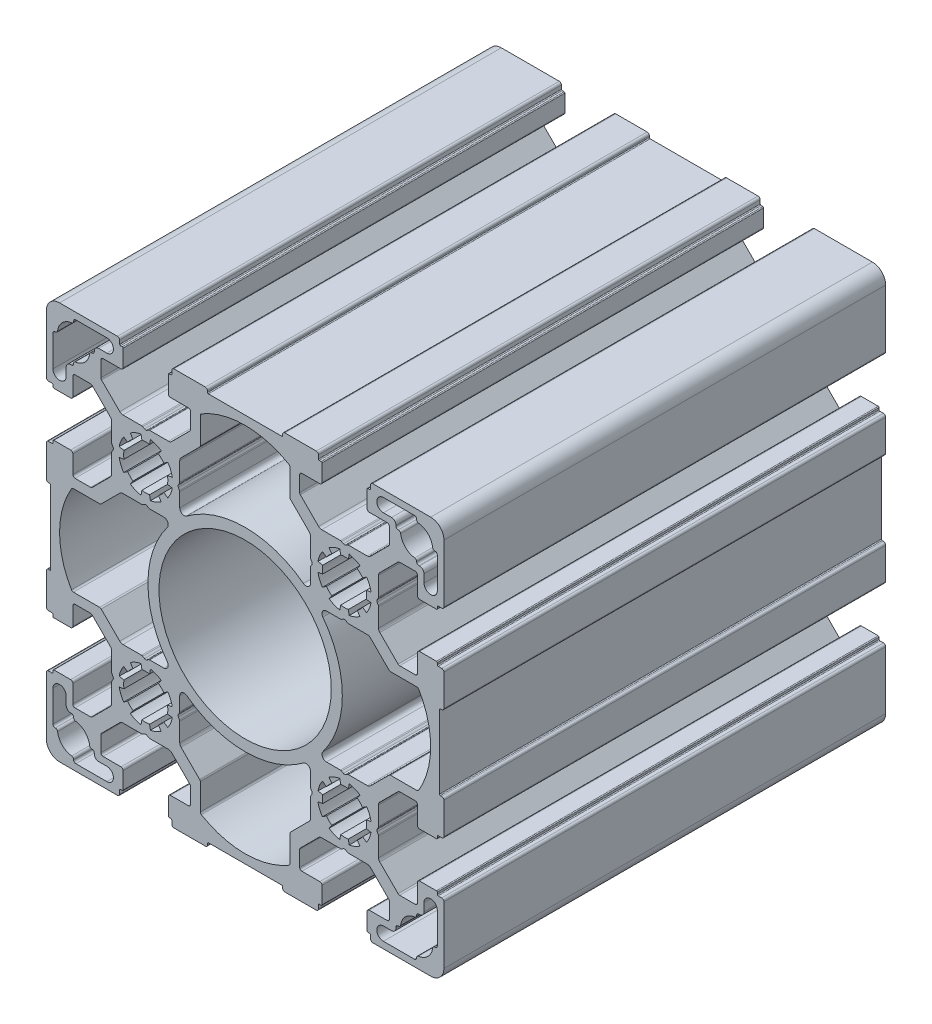
from build123d import *

# Parameters (mm, degrees)
SKETCH_1_R      = 19.5
EXTRUDE_1_DEPTH = 100


with BuildPart() as part:
    # Эскиз1 → Бобышка-Вытянуть1 (new body)
    with BuildSketch(Plane.XY):
        with BuildLine():
            Line((-35.141853673, 36.152210307), (-35.141853673, 40.388068593))
            ThreePointArc((-35.141853673, 40.388068593), (-35.21797414, 40.770752026), (-35.434746892, 41.095175374))
            Line((-35.434746892, 41.095175374), (-37.681504654, 43.341933137))
            Line((-37.681504654, 43.341933137), (-39.566246974, 45.226675456))
            ThreePointArc((-39.566246974, 45.226675456), (-39.728458648, 45.335061832), (-39.919800364, 45.373122066))
            Line((-39.919800364, 45.373122066), (-43.441373239, 45.373122066))
            ThreePointArc((-43.441373239, 45.373122066), (-43.79492663, 45.226675456), (-43.941373239, 44.873122066))
            Line((-43.941373239, 44.873122066), (-43.941373239, 40.823122066))
            ThreePointArc((-43.941373239, 40.823122066), (-44.087819849, 40.469568675), (-44.441373239, 40.323122066))
            Line((-44.441373239, 40.323122066), (-48.241373239, 40.323122066))
            ThreePointArc((-48.241373239, 40.323122066), (-48.382794596, 40.381700709), (-48.441373239, 40.523122066))
            Line((-48.441373239, 40.523122066), (-48.441373239, 40.923122066))
            ThreePointArc((-48.441373239, 40.923122066), (-48.499951883, 41.064543422), (-48.641373239, 41.123122066))
            Line((-48.641373239, 41.123122066), (-49.441373239, 41.123122066))
            ThreePointArc((-49.441373239, 41.123122066), (-49.79492663, 41.269568675), (-49.941373239, 41.623122066))
            Line((-49.941373239, 41.623122066), (-49.941373239, 54.723122066))
            ThreePointArc((-49.941373239, 54.723122066), (-49.062693583, 56.844442409), (-46.941373239, 57.723122066))
            Line((-46.941373239, 57.723122066), (-33.841373239, 57.723122066))
            ThreePointArc((-33.841373239, 57.723122066), (-33.487819849, 57.576675456), (-33.341373239, 57.223122066))
            Line((-33.341373239, 57.223122066), (-33.341373239, 56.423122066))
            ThreePointArc((-33.341373239, 56.423122066), (-33.282794596, 56.281700709), (-33.141373239, 56.223122066))
            Line((-33.141373239, 56.223122066), (-32.741373239, 56.223122066))
            ThreePointArc((-32.741373239, 56.223122066), (-32.599951883, 56.164543422), (-32.541373239, 56.023122066))
            Line((-32.541373239, 56.023122066), (-32.541373239, 52.223122066))
            ThreePointArc((-32.541373239, 52.223122066), (-32.687819849, 51.869568675), (-33.041373239, 51.723122066))
            Line((-33.041373239, 51.723122066), (-37.091373239, 51.723122066))
            ThreePointArc((-37.091373239, 51.723122066), (-37.44492663, 51.576675456), (-37.591373239, 51.223122066))
            Line((-37.591373239, 51.223122066), (-37.591373239, 47.70154919))
            ThreePointArc((-37.591373239, 47.70154919), (-37.553313006, 47.510207474), (-37.44492663, 47.3479958))
            Line((-37.44492663, 47.3479958), (-35.560184311, 45.463253481))
            Line((-35.560184311, 45.463253481), (-33.313426548, 43.216495718))
            ThreePointArc((-33.313426548, 43.216495718), (-32.989003199, 42.999722967), (-32.606319767, 42.923602499))
            Line((-32.606319767, 42.923602499), (-28.370461481, 42.923602499))
            ThreePointArc((-28.370461481, 42.923602499), (-28.241051958, 42.906565412), (-28.120461481, 42.856615201))
            Line((-28.120461481, 42.856615201), (-27.691373239, 42.608880989))
            ThreePointArc((-27.691373239, 42.608880989), (-27.441373239, 42.541893691), (-27.191373239, 42.608880989))
            Line((-27.191373239, 42.608880989), (-26.762284998, 42.856615201))
            ThreePointArc((-26.762284998, 42.856615201), (-26.64169452, 42.906565412), (-26.512284998, 42.923602499))
            Line((-26.512284998, 42.923602499), (-22.276426712, 42.923602499))
            ThreePointArc((-22.276426712, 42.923602499), (-21.89374328, 42.999722967), (-21.569319931, 43.216495718))
            Line((-21.569319931, 43.216495718), (-19.322562168, 45.463253481))
            Line((-19.322562168, 45.463253481), (-17.437819849, 47.3479958))
            ThreePointArc((-17.437819849, 47.3479958), (-17.329433473, 47.510207474), (-17.291373239, 47.70154919))
            Line((-17.291373239, 47.70154919), (-17.291373239, 51.223122066))
            ThreePointArc((-17.291373239, 51.223122066), (-17.437819849, 51.576675456), (-17.791373239, 51.723122066))
            Line((-17.791373239, 51.723122066), (-21.841373239, 51.723122066))
            ThreePointArc((-21.841373239, 51.723122066), (-22.19492663, 51.869568675), (-22.341373239, 52.223122066))
            Line((-22.341373239, 52.223122066), (-22.341373239, 56.023122066))
            ThreePointArc((-22.341373239, 56.023122066), (-22.282794596, 56.164543422), (-22.141373239, 56.223122066))
            Line((-22.141373239, 56.223122066), (-21.741373239, 56.223122066))
            ThreePointArc((-21.741373239, 56.223122066), (-21.599951883, 56.281700709), (-21.541373239, 56.423122066))
            Line((-21.541373239, 56.423122066), (-21.541373239, 57.223122066))
            ThreePointArc((-21.541373239, 57.223122066), (-21.39492663, 57.576675456), (-21.041373239, 57.723122066))
            Line((-21.041373239, 57.723122066), (-13.941373239, 57.723122066))
            ThreePointArc((-13.941373239, 57.723122066), (-13.587819849, 57.576675456), (-13.441373239, 57.223122066))
            Line((-13.441373239, 57.223122066), (-13.441373239, 56.923122066))
            ThreePointArc((-13.441373239, 56.923122066), (-13.382794596, 56.781700709), (-13.241373239, 56.723122066))
            Line((-13.241373239, 56.723122066), (3.358626761, 56.723122066))
            ThreePointArc((3.358626761, 56.723122066), (3.500048117, 56.781700709), (3.558626761, 56.923122066))
            Line((3.558626761, 56.923122066), (3.558626761, 57.223122066))
            ThreePointArc((3.558626761, 57.223122066), (3.70507337, 57.576675456), (4.058626761, 57.723122066))
            Line((4.058626761, 57.723122066), (11.158626761, 57.723122066))
            ThreePointArc((11.158626761, 57.723122066), (11.512180151, 57.576675456), (11.658626761, 57.223122066))
            Line((11.658626761, 57.223122066), (11.658626761, 56.423122066))
            ThreePointArc((11.658626761, 56.423122066), (11.717205404, 56.281700709), (11.858626761, 56.223122066))
            Line((11.858626761, 56.223122066), (12.258626761, 56.223122066))
            ThreePointArc((12.258626761, 56.223122066), (12.400048117, 56.164543422), (12.458626761, 56.023122066))
            Line((12.458626761, 56.023122066), (12.458626761, 52.223122066))
            ThreePointArc((12.458626761, 52.223122066), (12.312180151, 51.869568675), (11.958626761, 51.723122066))
            Line((11.958626761, 51.723122066), (7.908626761, 51.723122066))
            ThreePointArc((7.908626761, 51.723122066), (7.55507337, 51.576675456), (7.408626761, 51.223122066))
            Line((7.408626761, 51.223122066), (7.408626761, 47.70154919))
            ThreePointArc((7.408626761, 47.70154919), (7.446686994, 47.510207474), (7.55507337, 47.3479958))
            Line((7.55507337, 47.3479958), (9.439815689, 45.463253481))
            Line((9.439815689, 45.463253481), (11.686573452, 43.216495718))
            ThreePointArc((11.686573452, 43.216495718), (12.010996801, 42.999722967), (12.393680233, 42.923602499))
            Line((12.393680233, 42.923602499), (16.629538519, 42.923602499))
            ThreePointArc((16.629538519, 42.923602499), (16.758948042, 42.906565412), (16.879538519, 42.856615201))
            Line((16.879538519, 42.856615201), (17.308626761, 42.608880989))
            ThreePointArc((17.308626761, 42.608880989), (17.558626761, 42.541893691), (17.808626761, 42.608880989))
            Line((17.808626761, 42.608880989), (18.237715002, 42.856615201))
            ThreePointArc((18.237715002, 42.856615201), (18.35830548, 42.906565412), (18.487715002, 42.923602499))
            Line((18.487715002, 42.923602499), (22.723573288, 42.923602499))
            ThreePointArc((22.723573288, 42.923602499), (23.10625672, 42.999722967), (23.430680069, 43.216495718))
            Line((23.430680069, 43.216495718), (25.677437832, 45.463253481))
            Line((25.677437832, 45.463253481), (27.562180151, 47.3479958))
            ThreePointArc((27.562180151, 47.3479958), (27.670566527, 47.510207474), (27.708626761, 47.70154919))
            Line((27.708626761, 47.70154919), (27.708626761, 51.223122066))
            ThreePointArc((27.708626761, 51.223122066), (27.562180151, 51.576675456), (27.208626761, 51.723122066))
            Line((27.208626761, 51.723122066), (23.158626761, 51.723122066))
            ThreePointArc((23.158626761, 51.723122066), (22.80507337, 51.869568675), (22.658626761, 52.223122066))
            Line((22.658626761, 52.223122066), (22.658626761, 56.023122066))
            ThreePointArc((22.658626761, 56.023122066), (22.717205404, 56.164543422), (22.858626761, 56.223122066))
            Line((22.858626761, 56.223122066), (23.258626761, 56.223122066))
            ThreePointArc((23.258626761, 56.223122066), (23.400048117, 56.281700709), (23.458626761, 56.423122066))
            Line((23.458626761, 56.423122066), (23.458626761, 57.223122066))
            ThreePointArc((23.458626761, 57.223122066), (23.60507337, 57.576675456), (23.958626761, 57.723122066))
            Line((23.958626761, 57.723122066), (37.058626761, 57.723122066))
            ThreePointArc((37.058626761, 57.723122066), (39.179947104, 56.844442409), (40.058626761, 54.723122066))
            Line((40.058626761, 54.723122066), (40.058626761, 41.623122066))
            ThreePointArc((40.058626761, 41.623122066), (39.912180151, 41.269568675), (39.558626761, 41.123122066))
            Line((39.558626761, 41.123122066), (38.758626761, 41.123122066))
            ThreePointArc((38.758626761, 41.123122066), (38.617205404, 41.064543422), (38.558626761, 40.923122066))
            Line((38.558626761, 40.923122066), (38.558626761, 40.523122066))
            ThreePointArc((38.558626761, 40.523122066), (38.500048117, 40.381700709), (38.358626761, 40.323122066))
            Line((38.358626761, 40.323122066), (34.558626761, 40.323122066))
            ThreePointArc((34.558626761, 40.323122066), (34.20507337, 40.469568675), (34.058626761, 40.823122066))
            Line((34.058626761, 40.823122066), (34.058626761, 44.873122066))
            ThreePointArc((34.058626761, 44.873122066), (33.912180151, 45.226675456), (33.558626761, 45.373122066))
            Line((33.558626761, 45.373122066), (30.037053885, 45.373122066))
            ThreePointArc((30.037053885, 45.373122066), (29.845712169, 45.335061832), (29.683500495, 45.226675456))
            Line((29.683500495, 45.226675456), (27.798758175, 43.341933137))
            Line((27.798758175, 43.341933137), (25.552000413, 41.095175374))
            ThreePointArc((25.552000413, 41.095175374), (25.335227661, 40.770752026), (25.259107194, 40.388068593))
            Line((25.259107194, 40.388068593), (25.259107194, 36.152210307))
            ThreePointArc((25.259107194, 36.152210307), (25.242070107, 36.022800785), (25.192119896, 35.902210307))
            Line((25.192119896, 35.902210307), (24.944385684, 35.473122066))
            ThreePointArc((24.944385684, 35.473122066), (24.877398386, 35.223122066), (24.944385684, 34.973122066))
            Line((24.944385684, 34.973122066), (25.192119896, 34.544033824))
            ThreePointArc((25.192119896, 34.544033824), (25.242070107, 34.423443347), (25.259107194, 34.294033824))
            Line((25.259107194, 34.294033824), (25.259107194, 30.058175538))
            ThreePointArc((25.259107194, 30.058175538), (25.335227661, 29.675492106), (25.552000413, 29.351068757))
            Line((25.552000413, 29.351068757), (27.798758175, 27.104310994))
            Line((27.798758175, 27.104310994), (29.683500495, 25.219568675))
            ThreePointArc((29.683500495, 25.219568675), (29.845712169, 25.111182299), (30.037053885, 25.073122066))
            Line((30.037053885, 25.073122066), (33.558626761, 25.073122066))
            ThreePointArc((33.558626761, 25.073122066), (33.912180151, 25.219568675), (34.058626761, 25.573122066))
            Line((34.058626761, 25.573122066), (34.058626761, 29.623122066))
            ThreePointArc((34.058626761, 29.623122066), (34.20507337, 29.976675456), (34.558626761, 30.123122066))
            Line((34.558626761, 30.123122066), (38.358626761, 30.123122066))
            ThreePointArc((38.358626761, 30.123122066), (38.500048117, 30.064543422), (38.558626761, 29.923122066))
            Line((38.558626761, 29.923122066), (38.558626761, 29.523122066))
            ThreePointArc((38.558626761, 29.523122066), (38.617205404, 29.381700709), (38.758626761, 29.323122066))
            Line((38.758626761, 29.323122066), (39.558626761, 29.323122066))
            ThreePointArc((39.558626761, 29.323122066), (39.912180151, 29.176675456), (40.058626761, 28.823122066))
            Line((40.058626761, 28.823122066), (40.058626761, 21.723122066))
            ThreePointArc((40.058626761, 21.723122066), (39.912180151, 21.369568675), (39.558626761, 21.223122066))
            Line((39.558626761, 21.223122066), (39.258626761, 21.223122066))
            ThreePointArc((39.258626761, 21.223122066), (39.117205404, 21.164543422), (39.058626761, 21.023122066))
            Line((39.058626761, 21.023122066), (39.058626761, 4.423122066))
            ThreePointArc((39.058626761, 4.423122066), (39.117205404, 4.281700709), (39.258626761, 4.223122066))
            Line((39.258626761, 4.223122066), (39.558626761, 4.223122066))
            ThreePointArc((39.558626761, 4.223122066), (39.912180151, 4.076675456), (40.058626761, 3.723122066))
            Line((40.058626761, 3.723122066), (40.058626761, -3.376877934))
            ThreePointArc((40.058626761, -3.376877934), (39.912180151, -3.730431325), (39.558626761, -3.876877934))
            Line((39.558626761, -3.876877934), (38.758626761, -3.876877934))
            ThreePointArc((38.758626761, -3.876877934), (38.617205404, -3.935456578), (38.558626761, -4.076877934))
            Line((38.558626761, -4.076877934), (38.558626761, -4.476877934))
            ThreePointArc((38.558626761, -4.476877934), (38.500048117, -4.618299291), (38.358626761, -4.676877934))
            Line((38.358626761, -4.676877934), (34.558626761, -4.676877934))
            ThreePointArc((34.558626761, -4.676877934), (34.20507337, -4.530431325), (34.058626761, -4.176877934))
            Line((34.058626761, -4.176877934), (34.058626761, -0.126877934))
            ThreePointArc((34.058626761, -0.126877934), (33.912180151, 0.226675456), (33.558626761, 0.373122066))
            Line((33.558626761, 0.373122066), (30.037053885, 0.373122066))
            ThreePointArc((30.037053885, 0.373122066), (29.845712169, 0.335061832), (29.683500495, 0.226675456))
            Line((29.683500495, 0.226675456), (27.798758175, -1.658066863))
            Line((27.798758175, -1.658066863), (25.552000413, -3.904824626))
            ThreePointArc((25.552000413, -3.904824626), (25.335227661, -4.229247974), (25.259107194, -4.611931407))
            Line((25.259107194, -4.611931407), (25.259107194, -8.847789693))
            ThreePointArc((25.259107194, -8.847789693), (25.242070107, -8.977199215), (25.192119896, -9.097789693))
            Line((25.192119896, -9.097789693), (24.944385684, -9.526877934))
            ThreePointArc((24.944385684, -9.526877934), (24.877398386, -9.776877934), (24.944385684, -10.026877934))
            Line((24.944385684, -10.026877934), (25.192119896, -10.455966176))
            ThreePointArc((25.192119896, -10.455966176), (25.242070107, -10.576556653), (25.259107194, -10.705966176))
            Line((25.259107194, -10.705966176), (25.259107194, -14.941824462))
            ThreePointArc((25.259107194, -14.941824462), (25.335227661, -15.324507894), (25.552000413, -15.648931243))
            Line((25.552000413, -15.648931243), (27.798758175, -17.895689006))
            Line((27.798758175, -17.895689006), (29.683500495, -19.780431325))
            ThreePointArc((29.683500495, -19.780431325), (29.845712169, -19.888817701), (30.037053885, -19.926877934))
            Line((30.037053885, -19.926877934), (33.558626761, -19.926877934))
            ThreePointArc((33.558626761, -19.926877934), (33.912180151, -19.780431325), (34.058626761, -19.426877934))
            Line((34.058626761, -19.426877934), (34.058626761, -15.376877934))
            ThreePointArc((34.058626761, -15.376877934), (34.20507337, -15.023324544), (34.558626761, -14.876877934))
            Line((34.558626761, -14.876877934), (38.358626761, -14.876877934))
            ThreePointArc((38.358626761, -14.876877934), (38.500048117, -14.935456578), (38.558626761, -15.076877934))
            Line((38.558626761, -15.076877934), (38.558626761, -15.476877934))
            ThreePointArc((38.558626761, -15.476877934), (38.617205404, -15.618299291), (38.758626761, -15.676877934))
            Line((38.758626761, -15.676877934), (39.558626761, -15.676877934))
            ThreePointArc((39.558626761, -15.676877934), (39.912180151, -15.823324544), (40.058626761, -16.176877934))
            Line((40.058626761, -16.176877934), (40.058626761, -29.276877934))
            ThreePointArc((40.058626761, -29.276877934), (39.179947104, -31.398198278), (37.058626761, -32.276877934))
            Line((37.058626761, -32.276877934), (23.958626761, -32.276877934))
            ThreePointArc((23.958626761, -32.276877934), (23.60507337, -32.130431325), (23.458626761, -31.776877934))
            Line((23.458626761, -31.776877934), (23.458626761, -30.976877934))
            ThreePointArc((23.458626761, -30.976877934), (23.400048117, -30.835456578), (23.258626761, -30.776877934))
            Line((23.258626761, -30.776877934), (22.858626761, -30.776877934))
            ThreePointArc((22.858626761, -30.776877934), (22.717205404, -30.718299291), (22.658626761, -30.576877934))
            Line((22.658626761, -30.576877934), (22.658626761, -26.776877934))
            ThreePointArc((22.658626761, -26.776877934), (22.80507337, -26.423324544), (23.158626761, -26.276877934))
            Line((23.158626761, -26.276877934), (27.208626761, -26.276877934))
            ThreePointArc((27.208626761, -26.276877934), (27.562180151, -26.130431325), (27.708626761, -25.776877934))
            Line((27.708626761, -25.776877934), (27.708626761, -22.255305059))
            ThreePointArc((27.708626761, -22.255305059), (27.670566527, -22.063963343), (27.562180151, -21.901751668))
            Line((27.562180151, -21.901751668), (25.677437832, -20.017009349))
            Line((25.677437832, -20.017009349), (23.430680069, -17.770251587))
            ThreePointArc((23.430680069, -17.770251587), (23.10625672, -17.553478835), (22.723573288, -17.477358368))
            Line((22.723573288, -17.477358368), (18.487715002, -17.477358368))
            ThreePointArc((18.487715002, -17.477358368), (18.35830548, -17.460321281), (18.237715002, -17.41037107))
            Line((18.237715002, -17.41037107), (17.808626761, -17.162636858))
            ThreePointArc((17.808626761, -17.162636858), (17.558626761, -17.09564956), (17.308626761, -17.162636858))
            Line((17.308626761, -17.162636858), (16.879538519, -17.41037107))
            ThreePointArc((16.879538519, -17.41037107), (16.758948042, -17.460321281), (16.629538519, -17.477358368))
            Line((16.629538519, -17.477358368), (12.393680233, -17.477358368))
            ThreePointArc((12.393680233, -17.477358368), (12.010996801, -17.553478835), (11.686573452, -17.770251587))
            Line((11.686573452, -17.770251587), (9.439815689, -20.017009349))
            Line((9.439815689, -20.017009349), (7.55507337, -21.901751668))
            ThreePointArc((7.55507337, -21.901751668), (7.446686994, -22.063963343), (7.408626761, -22.255305059))
            Line((7.408626761, -22.255305059), (7.408626761, -25.776877934))
            ThreePointArc((7.408626761, -25.776877934), (7.55507337, -26.130431325), (7.908626761, -26.276877934))
            Line((7.908626761, -26.276877934), (11.958626761, -26.276877934))
            ThreePointArc((11.958626761, -26.276877934), (12.312180151, -26.423324544), (12.458626761, -26.776877934))
            Line((12.458626761, -26.776877934), (12.458626761, -30.576877934))
            ThreePointArc((12.458626761, -30.576877934), (12.400048117, -30.718299291), (12.258626761, -30.776877934))
            Line((12.258626761, -30.776877934), (11.858626761, -30.776877934))
            ThreePointArc((11.858626761, -30.776877934), (11.717205404, -30.835456578), (11.658626761, -30.976877934))
            Line((11.658626761, -30.976877934), (11.658626761, -31.776877934))
            ThreePointArc((11.658626761, -31.776877934), (11.512180151, -32.130431325), (11.158626761, -32.276877934))
            Line((11.158626761, -32.276877934), (4.058626761, -32.276877934))
            ThreePointArc((4.058626761, -32.276877934), (3.70507337, -32.130431325), (3.558626761, -31.776877934))
            Line((3.558626761, -31.776877934), (3.558626761, -31.476877934))
            ThreePointArc((3.558626761, -31.476877934), (3.500048117, -31.335456578), (3.358626761, -31.276877934))
            Line((3.358626761, -31.276877934), (-13.241373239, -31.276877934))
            ThreePointArc((-13.241373239, -31.276877934), (-13.382794596, -31.335456578), (-13.441373239, -31.476877934))
            Line((-13.441373239, -31.476877934), (-13.441373239, -31.776877934))
            ThreePointArc((-13.441373239, -31.776877934), (-13.587819849, -32.130431325), (-13.941373239, -32.276877934))
            Line((-13.941373239, -32.276877934), (-21.041373239, -32.276877934))
            ThreePointArc((-21.041373239, -32.276877934), (-21.39492663, -32.130431325), (-21.541373239, -31.776877934))
            Line((-21.541373239, -31.776877934), (-21.541373239, -30.976877934))
            ThreePointArc((-21.541373239, -30.976877934), (-21.599951883, -30.835456578), (-21.741373239, -30.776877934))
            Line((-21.741373239, -30.776877934), (-22.141373239, -30.776877934))
            ThreePointArc((-22.141373239, -30.776877934), (-22.282794596, -30.718299291), (-22.341373239, -30.576877934))
            Line((-22.341373239, -30.576877934), (-22.341373239, -26.776877934))
            ThreePointArc((-22.341373239, -26.776877934), (-22.19492663, -26.423324544), (-21.841373239, -26.276877934))
            Line((-21.841373239, -26.276877934), (-17.791373239, -26.276877934))
            ThreePointArc((-17.791373239, -26.276877934), (-17.437819849, -26.130431325), (-17.291373239, -25.776877934))
            Line((-17.291373239, -25.776877934), (-17.291373239, -22.255305059))
            ThreePointArc((-17.291373239, -22.255305059), (-17.329433473, -22.063963343), (-17.437819849, -21.901751668))
            Line((-17.437819849, -21.901751668), (-19.322562168, -20.017009349))
            Line((-19.322562168, -20.017009349), (-21.569319931, -17.770251587))
            ThreePointArc((-21.569319931, -17.770251587), (-21.89374328, -17.553478835), (-22.276426712, -17.477358368))
            Line((-22.276426712, -17.477358368), (-26.512284998, -17.477358368))
            ThreePointArc((-26.512284998, -17.477358368), (-26.64169452, -17.460321281), (-26.762284998, -17.41037107))
            Line((-26.762284998, -17.41037107), (-27.191373239, -17.162636858))
            ThreePointArc((-27.191373239, -17.162636858), (-27.441373239, -17.09564956), (-27.691373239, -17.162636858))
            Line((-27.691373239, -17.162636858), (-28.120461481, -17.41037107))
            ThreePointArc((-28.120461481, -17.41037107), (-28.241051958, -17.460321281), (-28.370461481, -17.477358368))
            Line((-28.370461481, -17.477358368), (-32.606319767, -17.477358368))
            ThreePointArc((-32.606319767, -17.477358368), (-32.989003199, -17.553478835), (-33.313426548, -17.770251587))
            Line((-33.313426548, -17.770251587), (-35.560184311, -20.017009349))
            Line((-35.560184311, -20.017009349), (-37.44492663, -21.901751668))
            ThreePointArc((-37.44492663, -21.901751668), (-37.553313006, -22.063963343), (-37.591373239, -22.255305059))
            Line((-37.591373239, -22.255305059), (-37.591373239, -25.776877934))
            ThreePointArc((-37.591373239, -25.776877934), (-37.44492663, -26.130431325), (-37.091373239, -26.276877934))
            Line((-37.091373239, -26.276877934), (-33.041373239, -26.276877934))
            ThreePointArc((-33.041373239, -26.276877934), (-32.687819849, -26.423324544), (-32.541373239, -26.776877934))
            Line((-32.541373239, -26.776877934), (-32.541373239, -30.576877934))
            ThreePointArc((-32.541373239, -30.576877934), (-32.599951883, -30.718299291), (-32.741373239, -30.776877934))
            Line((-32.741373239, -30.776877934), (-33.141373239, -30.776877934))
            ThreePointArc((-33.141373239, -30.776877934), (-33.282794596, -30.835456578), (-33.341373239, -30.976877934))
            Line((-33.341373239, -30.976877934), (-33.341373239, -31.776877934))
            ThreePointArc((-33.341373239, -31.776877934), (-33.487819849, -32.130431325), (-33.841373239, -32.276877934))
            Line((-33.841373239, -32.276877934), (-46.941373239, -32.276877934))
            ThreePointArc((-46.941373239, -32.276877934), (-49.062693583, -31.398198278), (-49.941373239, -29.276877934))
            Line((-49.941373239, -29.276877934), (-49.941373239, -16.176877934))
            ThreePointArc((-49.941373239, -16.176877934), (-49.79492663, -15.823324544), (-49.441373239, -15.676877934))
            Line((-49.441373239, -15.676877934), (-48.641373239, -15.676877934))
            ThreePointArc((-48.641373239, -15.676877934), (-48.499951883, -15.618299291), (-48.441373239, -15.476877934))
            Line((-48.441373239, -15.476877934), (-48.441373239, -15.076877934))
            ThreePointArc((-48.441373239, -15.076877934), (-48.382794596, -14.935456578), (-48.241373239, -14.876877934))
            Line((-48.241373239, -14.876877934), (-44.441373239, -14.876877934))
            ThreePointArc((-44.441373239, -14.876877934), (-44.087819849, -15.023324544), (-43.941373239, -15.376877934))
            Line((-43.941373239, -15.376877934), (-43.941373239, -19.426877934))
            ThreePointArc((-43.941373239, -19.426877934), (-43.79492663, -19.780431325), (-43.441373239, -19.926877934))
            Line((-43.441373239, -19.926877934), (-39.919800364, -19.926877934))
            ThreePointArc((-39.919800364, -19.926877934), (-39.728458648, -19.888817701), (-39.566246974, -19.780431325))
            Line((-39.566246974, -19.780431325), (-37.681504654, -17.895689006))
            Line((-37.681504654, -17.895689006), (-35.434746892, -15.648931243))
            ThreePointArc((-35.434746892, -15.648931243), (-35.21797414, -15.324507894), (-35.141853673, -14.941824462))
            Line((-35.141853673, -14.941824462), (-35.141853673, -10.705966176))
            ThreePointArc((-35.141853673, -10.705966176), (-35.124816586, -10.576556653), (-35.074866375, -10.455966176))
            Line((-35.074866375, -10.455966176), (-34.827132163, -10.026877934))
            ThreePointArc((-34.827132163, -10.026877934), (-34.760144865, -9.776877934), (-34.827132163, -9.526877934))
            Line((-34.827132163, -9.526877934), (-35.074866375, -9.097789693))
            ThreePointArc((-35.074866375, -9.097789693), (-35.124816586, -8.977199215), (-35.141853673, -8.847789693))
            Line((-35.141853673, -8.847789693), (-35.141853673, -4.611931407))
            ThreePointArc((-35.141853673, -4.611931407), (-35.21797414, -4.229247974), (-35.434746892, -3.904824626))
            Line((-35.434746892, -3.904824626), (-37.681504654, -1.658066863))
            Line((-37.681504654, -1.658066863), (-39.566246974, 0.226675456))
            ThreePointArc((-39.566246974, 0.226675456), (-39.728458648, 0.335061832), (-39.919800364, 0.373122066))
            Line((-39.919800364, 0.373122066), (-43.441373239, 0.373122066))
            ThreePointArc((-43.441373239, 0.373122066), (-43.79492663, 0.226675456), (-43.941373239, -0.126877934))
            Line((-43.941373239, -0.126877934), (-43.941373239, -4.176877934))
            ThreePointArc((-43.941373239, -4.176877934), (-44.087819849, -4.530431325), (-44.441373239, -4.676877934))
            Line((-44.441373239, -4.676877934), (-48.241373239, -4.676877934))
            ThreePointArc((-48.241373239, -4.676877934), (-48.382794596, -4.618299291), (-48.441373239, -4.476877934))
            Line((-48.441373239, -4.476877934), (-48.441373239, -4.076877934))
            ThreePointArc((-48.441373239, -4.076877934), (-48.499951883, -3.935456578), (-48.641373239, -3.876877934))
            Line((-48.641373239, -3.876877934), (-49.441373239, -3.876877934))
            ThreePointArc((-49.441373239, -3.876877934), (-49.79492663, -3.730431325), (-49.941373239, -3.376877934))
            Line((-49.941373239, -3.376877934), (-49.941373239, 3.723122066))
            ThreePointArc((-49.941373239, 3.723122066), (-49.79492663, 4.076675456), (-49.441373239, 4.223122066))
            Line((-49.441373239, 4.223122066), (-49.141373239, 4.223122066))
            ThreePointArc((-49.141373239, 4.223122066), (-48.999951883, 4.281700709), (-48.941373239, 4.423122066))
            Line((-48.941373239, 4.423122066), (-48.941373239, 21.023122066))
            ThreePointArc((-48.941373239, 21.023122066), (-48.999951883, 21.164543422), (-49.141373239, 21.223122066))
            Line((-49.141373239, 21.223122066), (-49.441373239, 21.223122066))
            ThreePointArc((-49.441373239, 21.223122066), (-49.79492663, 21.369568675), (-49.941373239, 21.723122066))
            Line((-49.941373239, 21.723122066), (-49.941373239, 28.823122066))
            ThreePointArc((-49.941373239, 28.823122066), (-49.79492663, 29.176675456), (-49.441373239, 29.323122066))
            Line((-49.441373239, 29.323122066), (-48.641373239, 29.323122066))
            ThreePointArc((-48.641373239, 29.323122066), (-48.499951883, 29.381700709), (-48.441373239, 29.523122066))
            Line((-48.441373239, 29.523122066), (-48.441373239, 29.923122066))
            ThreePointArc((-48.441373239, 29.923122066), (-48.382794596, 30.064543422), (-48.241373239, 30.123122066))
            Line((-48.241373239, 30.123122066), (-44.441373239, 30.123122066))
            ThreePointArc((-44.441373239, 30.123122066), (-44.087819849, 29.976675456), (-43.941373239, 29.623122066))
            Line((-43.941373239, 29.623122066), (-43.941373239, 25.573122066))
            ThreePointArc((-43.941373239, 25.573122066), (-43.79492663, 25.219568675), (-43.441373239, 25.073122066))
            Line((-43.441373239, 25.073122066), (-39.919800364, 25.073122066))
            ThreePointArc((-39.919800364, 25.073122066), (-39.728458648, 25.111182299), (-39.566246974, 25.219568675))
            Line((-39.566246974, 25.219568675), (-37.681504654, 27.104310994))
            Line((-37.681504654, 27.104310994), (-35.434746892, 29.351068757))
            ThreePointArc((-35.434746892, 29.351068757), (-35.21797414, 29.675492106), (-35.141853673, 30.058175538))
            Line((-35.141853673, 30.058175538), (-35.141853673, 34.294033824))
            ThreePointArc((-35.141853673, 34.294033824), (-35.124816586, 34.423443347), (-35.074866375, 34.544033824))
            Line((-35.074866375, 34.544033824), (-34.827132163, 34.973122066))
            ThreePointArc((-34.827132163, 34.973122066), (-34.760144865, 35.223122066), (-34.827132163, 35.473122066))
            Line((-34.827132163, 35.473122066), (-35.074866375, 35.902210307))
            ThreePointArc((-35.074866375, 35.902210307), (-35.124816586, 36.022800785), (-35.141853673, 36.152210307))
        make_face()
        with Locations((-4.941373239, 12.723122066)):
            Circle(SKETCH_1_R, mode=Mode.SUBTRACT)
        with BuildLine():
            Line((-48.441373239, 51.048122066), (-48.441373239, 44.031073139))
            ThreePointArc((-48.441373239, 44.031073139), (-46.941373239, 42.531073139), (-45.441373239, 44.031073139))
            Line((-45.441373239, 44.031073139), (-45.441373239, 45.873122066))
            ThreePointArc((-45.441373239, 45.873122066), (-45.148480021, 46.580228847), (-44.441373239, 46.873122066))
            Line((-44.441373239, 46.873122066), (-44.266373239, 46.873122066))
            ThreePointArc((-44.266373239, 46.873122066), (-43.912819849, 47.019568675), (-43.766373239, 47.373122066))
            Line((-43.766373239, 47.373122066), (-43.766373239, 47.428352655))
            ThreePointArc((-43.766373239, 47.428352655), (-43.64061947, 47.759924305), (-43.326614203, 47.924710415))
            ThreePointArc((-43.326614203, 47.924710415), (-41.185433488, 48.967182314), (-40.142961589, 51.10836303))
            ThreePointArc((-40.142961589, 51.10836303), (-39.978175478, 51.422368296), (-39.646603828, 51.548122066))
            Line((-39.646603828, 51.548122066), (-39.591373239, 51.548122066))
            ThreePointArc((-39.591373239, 51.548122066), (-39.237819849, 51.694568675), (-39.091373239, 52.048122066))
            Line((-39.091373239, 52.048122066), (-39.091373239, 52.223122066))
            ThreePointArc((-39.091373239, 52.223122066), (-38.798480021, 52.930228847), (-38.091373239, 53.223122066))
            Line((-38.091373239, 53.223122066), (-36.249324313, 53.223122066))
            ThreePointArc((-36.249324313, 53.223122066), (-34.749324313, 54.723122066), (-36.249324313, 56.223122066))
            Line((-36.249324313, 56.223122066), (-43.266373239, 56.223122066))
            ThreePointArc((-43.266373239, 56.223122066), (-43.61992663, 56.076675456), (-43.766373239, 55.723122066))
            Line((-43.766373239, 55.723122066), (-43.766373239, 55.667891477))
            ThreePointArc((-43.766373239, 55.667891477), (-43.892127009, 55.336319827), (-44.206132276, 55.171533716))
            ThreePointArc((-44.206132276, 55.171533716), (-46.347312991, 54.129061817), (-47.38978489, 51.987881102))
            ThreePointArc((-47.38978489, 51.987881102), (-47.554571001, 51.673875835), (-47.88614265, 51.548122066))
            Line((-47.88614265, 51.548122066), (-47.941373239, 51.548122066))
            ThreePointArc((-47.941373239, 51.548122066), (-48.29492663, 51.401675456), (-48.441373239, 51.048122066))
        make_face(mode=Mode.SUBTRACT)
        with BuildLine():
            Line((33.383626761, 56.223122066), (26.366577834, 56.223122066))
            ThreePointArc((26.366577834, 56.223122066), (24.866577834, 54.723122066), (26.366577834, 53.223122066))
            Line((26.366577834, 53.223122066), (28.208626761, 53.223122066))
            ThreePointArc((28.208626761, 53.223122066), (28.915733542, 52.930228847), (29.208626761, 52.223122066))
            Line((29.208626761, 52.223122066), (29.208626761, 52.048122066))
            ThreePointArc((29.208626761, 52.048122066), (29.35507337, 51.694568675), (29.708626761, 51.548122066))
            Line((29.708626761, 51.548122066), (29.76385735, 51.548122066))
            ThreePointArc((29.76385735, 51.548122066), (30.095428999, 51.422368296), (30.26021511, 51.10836303))
            ThreePointArc((30.26021511, 51.10836303), (31.302687009, 48.967182314), (33.443867724, 47.924710415))
            ThreePointArc((33.443867724, 47.924710415), (33.757872991, 47.759924305), (33.883626761, 47.428352655))
            Line((33.883626761, 47.428352655), (33.883626761, 47.373122066))
            ThreePointArc((33.883626761, 47.373122066), (34.03007337, 47.019568675), (34.383626761, 46.873122066))
            Line((34.383626761, 46.873122066), (34.558626761, 46.873122066))
            ThreePointArc((34.558626761, 46.873122066), (35.265733542, 46.580228847), (35.558626761, 45.873122066))
            Line((35.558626761, 45.873122066), (35.558626761, 44.031073139))
            ThreePointArc((35.558626761, 44.031073139), (37.058626761, 42.531073139), (38.558626761, 44.031073139))
            Line((38.558626761, 44.031073139), (38.558626761, 51.048122066))
            ThreePointArc((38.558626761, 51.048122066), (38.412180151, 51.401675456), (38.058626761, 51.548122066))
            Line((38.058626761, 51.548122066), (38.003396172, 51.548122066))
            ThreePointArc((38.003396172, 51.548122066), (37.671824522, 51.673875835), (37.507038411, 51.987881102))
            ThreePointArc((37.507038411, 51.987881102), (36.464566512, 54.129061817), (34.323385797, 55.171533716))
            ThreePointArc((34.323385797, 55.171533716), (34.00938053, 55.336319827), (33.883626761, 55.667891477))
            Line((33.883626761, 55.667891477), (33.883626761, 55.723122066))
            ThreePointArc((33.883626761, 55.723122066), (33.737180151, 56.076675456), (33.383626761, 56.223122066))
        make_face(mode=Mode.SUBTRACT)
        with BuildLine():
            Line((-15.091373239, 49.462335628), (-15.091373239, 45.658908503))
            ThreePointArc((-15.091373239, 45.658908503), (-15.129433473, 45.467566787), (-15.237819849, 45.305355113))
            Line((-15.237819849, 45.305355113), (-17.201241825, 43.341933137))
            Line((-17.201241825, 43.341933137), (-19.447999587, 41.095175374))
            ThreePointArc((-19.447999587, 41.095175374), (-19.664772339, 40.770752026), (-19.740892806, 40.388068593))
            Line((-19.740892806, 40.388068593), (-19.740892806, 36.152210307))
            ThreePointArc((-19.740892806, 36.152210307), (-19.757929893, 36.022800785), (-19.807880104, 35.902210307))
            Line((-19.807880104, 35.902210307), (-20.055614316, 35.473122066))
            ThreePointArc((-20.055614316, 35.473122066), (-20.122601614, 35.223122066), (-20.055614316, 34.973122066))
            Line((-20.055614316, 34.973122066), (-19.807880104, 34.544033824))
            ThreePointArc((-19.807880104, 34.544033824), (-19.757929893, 34.423443347), (-19.740892806, 34.294033824))
            Line((-19.740892806, 34.294033824), (-19.740892806, 31.123482381))
            ThreePointArc((-19.740892806, 31.123482381), (-19.188118078, 30.229061029), (-18.140913694, 30.323466715))
            ThreePointArc((-18.140913694, 30.323466715), (-4.941373239, 34.723122066), (8.258167216, 30.323466715))
            ThreePointArc((8.258167216, 30.323466715), (9.305371599, 30.229061029), (9.858146327, 31.123482381))
            Line((9.858146327, 31.123482381), (9.858146327, 34.294033824))
            ThreePointArc((9.858146327, 34.294033824), (9.875183414, 34.423443347), (9.925133625, 34.544033824))
            Line((9.925133625, 34.544033824), (10.172867837, 34.973122066))
            ThreePointArc((10.172867837, 34.973122066), (10.239855135, 35.223122066), (10.172867837, 35.473122066))
            Line((10.172867837, 35.473122066), (9.925133625, 35.902210307))
            ThreePointArc((9.925133625, 35.902210307), (9.875183414, 36.022800785), (9.858146327, 36.152210307))
            Line((9.858146327, 36.152210307), (9.858146327, 40.388068593))
            ThreePointArc((9.858146327, 40.388068593), (9.78202586, 40.770752026), (9.565253108, 41.095175374))
            Line((9.565253108, 41.095175374), (7.318495346, 43.341933137))
            Line((7.318495346, 43.341933137), (5.35507337, 45.305355113))
            ThreePointArc((5.35507337, 45.305355113), (5.246686994, 45.467566787), (5.208626761, 45.658908503))
            Line((5.208626761, 45.658908503), (5.208626761, 49.462335628))
            Line((5.208626761, 49.462335628), (5.208626761, 51.590085743))
            ThreePointArc((5.208626761, 51.590085743), (5.142777474, 51.838104205), (4.962574129, 52.020795313))
            ThreePointArc((4.962574129, 52.020795313), (-4.941373239, 54.723122066), (-14.845320608, 52.020795313))
            ThreePointArc((-14.845320608, 52.020795313), (-15.025523953, 51.838104205), (-15.091373239, 51.590085743))
            Line((-15.091373239, 51.590085743), (-15.091373239, 49.462335628))
        make_face(mode=Mode.SUBTRACT)
        with BuildLine():
            Line((-30.309255421, 39.318882287), (-30.940189501, 40.219949536))
            ThreePointArc((-30.940189501, 40.219949536), (-29.775742177, 40.858787214), (-28.500627123, 41.230449359))
            Line((-28.500627123, 41.230449359), (-28.309614128, 40.147160831))
            ThreePointArc((-28.309614128, 40.147160831), (-27.441373239, 40.223122066), (-26.573132351, 40.147160831))
            Line((-26.573132351, 40.147160831), (-26.382119356, 41.230449359))
            ThreePointArc((-26.382119356, 41.230449359), (-25.107004302, 40.858787214), (-23.942556978, 40.219949536))
            Line((-23.942556978, 40.219949536), (-24.573491058, 39.318882287))
            ThreePointArc((-24.573491058, 39.318882287), (-23.905839334, 38.758655972), (-23.345613018, 38.091004247))
            Line((-23.345613018, 38.091004247), (-22.444545769, 38.721938327))
            ThreePointArc((-22.444545769, 38.721938327), (-21.805708091, 37.557491003), (-21.434045946, 36.282375949))
            Line((-21.434045946, 36.282375949), (-22.517334474, 36.091362954))
            ThreePointArc((-22.517334474, 36.091362954), (-22.441373239, 35.223122066), (-22.517334474, 34.354881177))
            Line((-22.517334474, 34.354881177), (-21.434045946, 34.163868182))
            ThreePointArc((-21.434045946, 34.163868182), (-21.805708091, 32.888753128), (-22.444545769, 31.724305804))
            Line((-22.444545769, 31.724305804), (-23.345613018, 32.355239884))
            ThreePointArc((-23.345613018, 32.355239884), (-23.905839334, 31.68758816), (-24.573491058, 31.127361844))
            Line((-24.573491058, 31.127361844), (-23.942556978, 30.226294596))
            ThreePointArc((-23.942556978, 30.226294596), (-25.107004302, 29.587456917), (-26.382119356, 29.215794772))
            Line((-26.382119356, 29.215794772), (-26.573132351, 30.299083301))
            ThreePointArc((-26.573132351, 30.299083301), (-27.441373239, 30.223122066), (-28.309614128, 30.299083301))
            Line((-28.309614128, 30.299083301), (-28.500627123, 29.215794772))
            ThreePointArc((-28.500627123, 29.215794772), (-29.775742177, 29.587456917), (-30.940189501, 30.226294596))
            Line((-30.940189501, 30.226294596), (-30.309255421, 31.127361844))
            ThreePointArc((-30.309255421, 31.127361844), (-30.976907145, 31.68758816), (-31.537133461, 32.355239884))
            Line((-31.537133461, 32.355239884), (-32.43820071, 31.724305804))
            ThreePointArc((-32.43820071, 31.724305804), (-33.077038388, 32.888753128), (-33.448700533, 34.163868182))
            Line((-33.448700533, 34.163868182), (-32.365412004, 34.354881177))
            ThreePointArc((-32.365412004, 34.354881177), (-32.441373239, 35.223122066), (-32.365412004, 36.091362954))
            Line((-32.365412004, 36.091362954), (-33.448700533, 36.282375949))
            ThreePointArc((-33.448700533, 36.282375949), (-33.077038388, 37.557491003), (-32.43820071, 38.721938327))
            Line((-32.43820071, 38.721938327), (-31.537133461, 38.091004247))
            ThreePointArc((-31.537133461, 38.091004247), (-30.976907145, 38.758655972), (-30.309255421, 39.318882287))
        make_face(mode=Mode.SUBTRACT)
        with BuildLine():
            Line((16.629538519, 27.522641632), (13.458987076, 27.522641632))
            ThreePointArc((13.458987076, 27.522641632), (12.564565723, 26.969866905), (12.65897141, 25.922662521))
            ThreePointArc((12.65897141, 25.922662521), (17.058626761, 12.723122066), (12.65897141, -0.476418389))
            ThreePointArc((12.65897141, -0.476418389), (12.564565723, -1.523622773), (13.458987076, -2.076397501))
            Line((13.458987076, -2.076397501), (16.629538519, -2.076397501))
            ThreePointArc((16.629538519, -2.076397501), (16.758948042, -2.093434588), (16.879538519, -2.143384799))
            Line((16.879538519, -2.143384799), (17.308626761, -2.391119011))
            ThreePointArc((17.308626761, -2.391119011), (17.558626761, -2.458106309), (17.808626761, -2.391119011))
            Line((17.808626761, -2.391119011), (18.237715002, -2.143384799))
            ThreePointArc((18.237715002, -2.143384799), (18.35830548, -2.093434588), (18.487715002, -2.076397501))
            Line((18.487715002, -2.076397501), (22.723573288, -2.076397501))
            ThreePointArc((22.723573288, -2.076397501), (23.10625672, -2.000277033), (23.430680069, -1.783504282))
            Line((23.430680069, -1.783504282), (25.677437832, 0.463253481))
            Line((25.677437832, 0.463253481), (27.640859808, 2.426675456))
            ThreePointArc((27.640859808, 2.426675456), (27.803071482, 2.535061832), (27.994413198, 2.573122066))
            Line((27.994413198, 2.573122066), (31.797840323, 2.573122066))
            Line((31.797840323, 2.573122066), (33.925590437, 2.573122066))
            ThreePointArc((33.925590437, 2.573122066), (34.1736089, 2.638971352), (34.356300008, 2.819174697))
            ThreePointArc((34.356300008, 2.819174697), (37.058626761, 12.723122066), (34.356300008, 22.627069434))
            ThreePointArc((34.356300008, 22.627069434), (34.1736089, 22.807272779), (33.925590437, 22.873122066))
            Line((33.925590437, 22.873122066), (31.797840323, 22.873122066))
            Line((31.797840323, 22.873122066), (27.994413198, 22.873122066))
            ThreePointArc((27.994413198, 22.873122066), (27.803071482, 22.911182299), (27.640859808, 23.019568675))
            Line((27.640859808, 23.019568675), (25.677437832, 24.982990651))
            Line((25.677437832, 24.982990651), (23.430680069, 27.229748413))
            ThreePointArc((23.430680069, 27.229748413), (23.10625672, 27.446521165), (22.723573288, 27.522641632))
            Line((22.723573288, 27.522641632), (18.487715002, 27.522641632))
            ThreePointArc((18.487715002, 27.522641632), (18.35830548, 27.539678719), (18.237715002, 27.58962893))
            Line((18.237715002, 27.58962893), (17.808626761, 27.837363142))
            ThreePointArc((17.808626761, 27.837363142), (17.558626761, 27.90435044), (17.308626761, 27.837363142))
            Line((17.308626761, 27.837363142), (16.879538519, 27.58962893))
            ThreePointArc((16.879538519, 27.58962893), (16.758948042, 27.539678719), (16.629538519, 27.522641632))
        make_face(mode=Mode.SUBTRACT)
        with BuildLine():
            Line((-28.370461481, 27.522641632), (-32.606319767, 27.522641632))
            ThreePointArc((-32.606319767, 27.522641632), (-32.989003199, 27.446521165), (-33.313426548, 27.229748413))
            Line((-33.313426548, 27.229748413), (-35.560184311, 24.982990651))
            Line((-35.560184311, 24.982990651), (-37.523606286, 23.019568675))
            ThreePointArc((-37.523606286, 23.019568675), (-37.685817961, 22.911182299), (-37.877159677, 22.873122066))
            Line((-37.877159677, 22.873122066), (-41.680586802, 22.873122066))
            Line((-41.680586802, 22.873122066), (-43.808336916, 22.873122066))
            ThreePointArc((-43.808336916, 22.873122066), (-44.056355379, 22.807272779), (-44.239046487, 22.627069434))
            ThreePointArc((-44.239046487, 22.627069434), (-46.941373239, 12.723122066), (-44.239046487, 2.819174697))
            ThreePointArc((-44.239046487, 2.819174697), (-44.056355379, 2.638971352), (-43.808336916, 2.573122066))
            Line((-43.808336916, 2.573122066), (-41.680586802, 2.573122066))
            Line((-41.680586802, 2.573122066), (-37.877159677, 2.573122066))
            ThreePointArc((-37.877159677, 2.573122066), (-37.685817961, 2.535061832), (-37.523606286, 2.426675456))
            Line((-37.523606286, 2.426675456), (-35.560184311, 0.463253481))
            Line((-35.560184311, 0.463253481), (-33.313426548, -1.783504282))
            ThreePointArc((-33.313426548, -1.783504282), (-32.989003199, -2.000277033), (-32.606319767, -2.076397501))
            Line((-32.606319767, -2.076397501), (-28.370461481, -2.076397501))
            ThreePointArc((-28.370461481, -2.076397501), (-28.241051958, -2.093434588), (-28.120461481, -2.143384799))
            Line((-28.120461481, -2.143384799), (-27.691373239, -2.391119011))
            ThreePointArc((-27.691373239, -2.391119011), (-27.441373239, -2.458106309), (-27.191373239, -2.391119011))
            Line((-27.191373239, -2.391119011), (-26.762284998, -2.143384799))
            ThreePointArc((-26.762284998, -2.143384799), (-26.64169452, -2.093434588), (-26.512284998, -2.076397501))
            Line((-26.512284998, -2.076397501), (-23.341733555, -2.076397501))
            ThreePointArc((-23.341733555, -2.076397501), (-22.447312202, -1.523622773), (-22.541717889, -0.476418389))
            ThreePointArc((-22.541717889, -0.476418389), (-26.941373239, 12.723122066), (-22.541717889, 25.922662521))
            ThreePointArc((-22.541717889, 25.922662521), (-22.447312202, 26.969866905), (-23.341733555, 27.522641632))
            Line((-23.341733555, 27.522641632), (-26.512284998, 27.522641632))
            ThreePointArc((-26.512284998, 27.522641632), (-26.64169452, 27.539678719), (-26.762284998, 27.58962893))
            Line((-26.762284998, 27.58962893), (-27.191373239, 27.837363142))
            ThreePointArc((-27.191373239, 27.837363142), (-27.441373239, 27.90435044), (-27.691373239, 27.837363142))
            Line((-27.691373239, 27.837363142), (-28.120461481, 27.58962893))
            ThreePointArc((-28.120461481, 27.58962893), (-28.241051958, 27.539678719), (-28.370461481, 27.522641632))
        make_face(mode=Mode.SUBTRACT)
        with BuildLine():
            Line((21.654386982, 38.091004247), (22.555454231, 38.721938327))
            ThreePointArc((22.555454231, 38.721938327), (23.194291909, 37.557491003), (23.565954054, 36.282375949))
            Line((23.565954054, 36.282375949), (22.482665526, 36.091362954))
            ThreePointArc((22.482665526, 36.091362954), (22.558626761, 35.223122066), (22.482665526, 34.354881177))
            Line((22.482665526, 34.354881177), (23.565954054, 34.163868182))
            ThreePointArc((23.565954054, 34.163868182), (23.194291909, 32.888753128), (22.555454231, 31.724305804))
            Line((22.555454231, 31.724305804), (21.654386982, 32.355239884))
            ThreePointArc((21.654386982, 32.355239884), (21.094160666, 31.68758816), (20.426508942, 31.127361844))
            Line((20.426508942, 31.127361844), (21.057443022, 30.226294596))
            ThreePointArc((21.057443022, 30.226294596), (19.892995698, 29.587456917), (18.617880644, 29.215794772))
            Line((18.617880644, 29.215794772), (18.426867649, 30.299083301))
            ThreePointArc((18.426867649, 30.299083301), (17.558626761, 30.223122066), (16.690385872, 30.299083301))
            Line((16.690385872, 30.299083301), (16.499372877, 29.215794772))
            ThreePointArc((16.499372877, 29.215794772), (15.224257823, 29.587456917), (14.059810499, 30.226294596))
            Line((14.059810499, 30.226294596), (14.690744579, 31.127361844))
            ThreePointArc((14.690744579, 31.127361844), (14.023092855, 31.68758816), (13.462866539, 32.355239884))
            Line((13.462866539, 32.355239884), (12.56179929, 31.724305804))
            ThreePointArc((12.56179929, 31.724305804), (11.922961612, 32.888753128), (11.551299467, 34.163868182))
            Line((11.551299467, 34.163868182), (12.634587996, 34.354881177))
            ThreePointArc((12.634587996, 34.354881177), (12.558626761, 35.223122066), (12.634587996, 36.091362954))
            Line((12.634587996, 36.091362954), (11.551299467, 36.282375949))
            ThreePointArc((11.551299467, 36.282375949), (11.922961612, 37.557491003), (12.56179929, 38.721938327))
            Line((12.56179929, 38.721938327), (13.462866539, 38.091004247))
            ThreePointArc((13.462866539, 38.091004247), (14.023092855, 38.758655972), (14.690744579, 39.318882287))
            Line((14.690744579, 39.318882287), (14.059810499, 40.219949536))
            ThreePointArc((14.059810499, 40.219949536), (15.224257823, 40.858787214), (16.499372877, 41.230449359))
            Line((16.499372877, 41.230449359), (16.690385872, 40.147160831))
            ThreePointArc((16.690385872, 40.147160831), (17.558626761, 40.223122066), (18.426867649, 40.147160831))
            Line((18.426867649, 40.147160831), (18.617880644, 41.230449359))
            ThreePointArc((18.617880644, 41.230449359), (19.892995698, 40.858787214), (21.057443022, 40.219949536))
            Line((21.057443022, 40.219949536), (20.426508942, 39.318882287))
            ThreePointArc((20.426508942, 39.318882287), (21.094160666, 38.758655972), (21.654386982, 38.091004247))
        make_face(mode=Mode.SUBTRACT)
        with BuildLine():
            Line((13.462866539, -12.644760116), (12.56179929, -13.275694196))
            ThreePointArc((12.56179929, -13.275694196), (11.922961612, -12.111246872), (11.551299467, -10.836131818))
            Line((11.551299467, -10.836131818), (12.634587996, -10.645118823))
            ThreePointArc((12.634587996, -10.645118823), (12.558626761, -9.776877934), (12.634587996, -8.908637046))
            Line((12.634587996, -8.908637046), (11.551299467, -8.717624051))
            ThreePointArc((11.551299467, -8.717624051), (11.922961612, -7.442508997), (12.56179929, -6.278061673))
            Line((12.56179929, -6.278061673), (13.462866539, -6.908995753))
            ThreePointArc((13.462866539, -6.908995753), (14.023092855, -6.241344028), (14.690744579, -5.681117713))
            Line((14.690744579, -5.681117713), (14.059810499, -4.780050464))
            ThreePointArc((14.059810499, -4.780050464), (15.224257823, -4.141212786), (16.499372877, -3.769550641))
            Line((16.499372877, -3.769550641), (16.690385872, -4.852839169))
            ThreePointArc((16.690385872, -4.852839169), (17.558626761, -4.776877934), (18.426867649, -4.852839169))
            Line((18.426867649, -4.852839169), (18.617880644, -3.769550641))
            ThreePointArc((18.617880644, -3.769550641), (19.892995698, -4.141212786), (21.057443022, -4.780050464))
            Line((21.057443022, -4.780050464), (20.426508942, -5.681117713))
            ThreePointArc((20.426508942, -5.681117713), (21.094160666, -6.241344028), (21.654386982, -6.908995753))
            Line((21.654386982, -6.908995753), (22.555454231, -6.278061673))
            ThreePointArc((22.555454231, -6.278061673), (23.194291909, -7.442508997), (23.565954054, -8.717624051))
            Line((23.565954054, -8.717624051), (22.482665526, -8.908637046))
            ThreePointArc((22.482665526, -8.908637046), (22.558626761, -9.776877934), (22.482665526, -10.645118823))
            Line((22.482665526, -10.645118823), (23.565954054, -10.836131818))
            ThreePointArc((23.565954054, -10.836131818), (23.194291909, -12.111246872), (22.555454231, -13.275694196))
            Line((22.555454231, -13.275694196), (21.654386982, -12.644760116))
            ThreePointArc((21.654386982, -12.644760116), (21.094160666, -13.31241184), (20.426508942, -13.872638156))
            Line((20.426508942, -13.872638156), (21.057443022, -14.773705404))
            ThreePointArc((21.057443022, -14.773705404), (19.892995698, -15.412543083), (18.617880644, -15.784205228))
            Line((18.617880644, -15.784205228), (18.426867649, -14.700916699))
            ThreePointArc((18.426867649, -14.700916699), (17.558626761, -14.776877934), (16.690385872, -14.700916699))
            Line((16.690385872, -14.700916699), (16.499372877, -15.784205228))
            ThreePointArc((16.499372877, -15.784205228), (15.224257823, -15.412543083), (14.059810499, -14.773705404))
            Line((14.059810499, -14.773705404), (14.690744579, -13.872638156))
            ThreePointArc((14.690744579, -13.872638156), (14.023092855, -13.31241184), (13.462866539, -12.644760116))
        make_face(mode=Mode.SUBTRACT)
        with BuildLine():
            Line((10.172867837, -9.526877934), (9.925133625, -9.097789693))
            ThreePointArc((9.925133625, -9.097789693), (9.875183414, -8.977199215), (9.858146327, -8.847789693))
            Line((9.858146327, -8.847789693), (9.858146327, -5.67723825))
            ThreePointArc((9.858146327, -5.67723825), (9.305371599, -4.782816897), (8.258167216, -4.877222584))
            ThreePointArc((8.258167216, -4.877222584), (-4.941373239, -9.276877934), (-18.140913694, -4.877222584))
            ThreePointArc((-18.140913694, -4.877222584), (-19.188118078, -4.782816897), (-19.740892806, -5.67723825))
            Line((-19.740892806, -5.67723825), (-19.740892806, -8.847789693))
            ThreePointArc((-19.740892806, -8.847789693), (-19.757929893, -8.977199215), (-19.807880104, -9.097789693))
            Line((-19.807880104, -9.097789693), (-20.055614316, -9.526877934))
            ThreePointArc((-20.055614316, -9.526877934), (-20.122601614, -9.776877934), (-20.055614316, -10.026877934))
            Line((-20.055614316, -10.026877934), (-19.807880104, -10.455966176))
            ThreePointArc((-19.807880104, -10.455966176), (-19.757929893, -10.576556653), (-19.740892806, -10.705966176))
            Line((-19.740892806, -10.705966176), (-19.740892806, -14.941824462))
            ThreePointArc((-19.740892806, -14.941824462), (-19.664772339, -15.324507894), (-19.447999587, -15.648931243))
            Line((-19.447999587, -15.648931243), (-17.201241825, -17.895689006))
            Line((-17.201241825, -17.895689006), (-15.237819849, -19.859110981))
            ThreePointArc((-15.237819849, -19.859110981), (-15.129433473, -20.021322656), (-15.091373239, -20.212664372))
            Line((-15.091373239, -20.212664372), (-15.091373239, -24.016091497))
            Line((-15.091373239, -24.016091497), (-15.091373239, -26.143841611))
            ThreePointArc((-15.091373239, -26.143841611), (-15.025523953, -26.391860074), (-14.845320608, -26.574551182))
            ThreePointArc((-14.845320608, -26.574551182), (-4.941373239, -29.276877934), (4.962574129, -26.574551182))
            ThreePointArc((4.962574129, -26.574551182), (5.142777474, -26.391860074), (5.208626761, -26.143841611))
            Line((5.208626761, -26.143841611), (5.208626761, -24.016091497))
            Line((5.208626761, -24.016091497), (5.208626761, -20.212664372))
            ThreePointArc((5.208626761, -20.212664372), (5.246686994, -20.021322656), (5.35507337, -19.859110981))
            Line((5.35507337, -19.859110981), (7.318495346, -17.895689006))
            Line((7.318495346, -17.895689006), (9.565253108, -15.648931243))
            ThreePointArc((9.565253108, -15.648931243), (9.78202586, -15.324507894), (9.858146327, -14.941824462))
            Line((9.858146327, -14.941824462), (9.858146327, -10.705966176))
            ThreePointArc((9.858146327, -10.705966176), (9.875183414, -10.576556653), (9.925133625, -10.455966176))
            Line((9.925133625, -10.455966176), (10.172867837, -10.026877934))
            ThreePointArc((10.172867837, -10.026877934), (10.239855135, -9.776877934), (10.172867837, -9.526877934))
        make_face(mode=Mode.SUBTRACT)
        with BuildLine():
            Line((38.558626761, -25.601877934), (38.558626761, -18.584829008))
            ThreePointArc((38.558626761, -18.584829008), (37.058626761, -17.084829008), (35.558626761, -18.584829008))
            Line((35.558626761, -18.584829008), (35.558626761, -20.426877934))
            ThreePointArc((35.558626761, -20.426877934), (35.265733542, -21.133984715), (34.558626761, -21.426877934))
            Line((34.558626761, -21.426877934), (34.383626761, -21.426877934))
            ThreePointArc((34.383626761, -21.426877934), (34.03007337, -21.573324544), (33.883626761, -21.926877934))
            Line((33.883626761, -21.926877934), (33.883626761, -21.982108523))
            ThreePointArc((33.883626761, -21.982108523), (33.757872991, -22.313680173), (33.443867724, -22.478466284))
            ThreePointArc((33.443867724, -22.478466284), (31.302687009, -23.520938183), (30.26021511, -25.662118898))
            ThreePointArc((30.26021511, -25.662118898), (30.095428999, -25.976124165), (29.76385735, -26.101877934))
            Line((29.76385735, -26.101877934), (29.708626761, -26.101877934))
            ThreePointArc((29.708626761, -26.101877934), (29.35507337, -26.248324544), (29.208626761, -26.601877934))
            Line((29.208626761, -26.601877934), (29.208626761, -26.776877934))
            ThreePointArc((29.208626761, -26.776877934), (28.915733542, -27.483984715), (28.208626761, -27.776877934))
            Line((28.208626761, -27.776877934), (26.366577834, -27.776877934))
            ThreePointArc((26.366577834, -27.776877934), (24.866577834, -29.276877934), (26.366577834, -30.776877934))
            Line((26.366577834, -30.776877934), (33.383626761, -30.776877934))
            ThreePointArc((33.383626761, -30.776877934), (33.737180151, -30.630431325), (33.883626761, -30.276877934))
            Line((33.883626761, -30.276877934), (33.883626761, -30.221647345))
            ThreePointArc((33.883626761, -30.221647345), (34.00938053, -29.890075695), (34.323385797, -29.725289585))
            ThreePointArc((34.323385797, -29.725289585), (36.464566512, -28.682817686), (37.507038411, -26.54163697))
            ThreePointArc((37.507038411, -26.54163697), (37.671824522, -26.227631704), (38.003396172, -26.101877934))
            Line((38.003396172, -26.101877934), (38.058626761, -26.101877934))
            ThreePointArc((38.058626761, -26.101877934), (38.412180151, -25.955431325), (38.558626761, -25.601877934))
        make_face(mode=Mode.SUBTRACT)
        with BuildLine():
            Line((-30.309255421, -5.681117713), (-30.940189501, -4.780050464))
            ThreePointArc((-30.940189501, -4.780050464), (-29.775742177, -4.141212786), (-28.500627123, -3.769550641))
            Line((-28.500627123, -3.769550641), (-28.309614128, -4.852839169))
            ThreePointArc((-28.309614128, -4.852839169), (-27.441373239, -4.776877934), (-26.573132351, -4.852839169))
            Line((-26.573132351, -4.852839169), (-26.382119356, -3.769550641))
            ThreePointArc((-26.382119356, -3.769550641), (-25.107004302, -4.141212786), (-23.942556978, -4.780050464))
            Line((-23.942556978, -4.780050464), (-24.573491058, -5.681117713))
            ThreePointArc((-24.573491058, -5.681117713), (-23.905839334, -6.241344028), (-23.345613018, -6.908995753))
            Line((-23.345613018, -6.908995753), (-22.444545769, -6.278061673))
            ThreePointArc((-22.444545769, -6.278061673), (-21.805708091, -7.442508997), (-21.434045946, -8.717624051))
            Line((-21.434045946, -8.717624051), (-22.517334474, -8.908637046))
            ThreePointArc((-22.517334474, -8.908637046), (-22.441373239, -9.776877934), (-22.517334474, -10.645118823))
            Line((-22.517334474, -10.645118823), (-21.434045946, -10.836131818))
            ThreePointArc((-21.434045946, -10.836131818), (-21.805708091, -12.111246872), (-22.444545769, -13.275694196))
            Line((-22.444545769, -13.275694196), (-23.345613018, -12.644760116))
            ThreePointArc((-23.345613018, -12.644760116), (-23.905839334, -13.31241184), (-24.573491058, -13.872638156))
            Line((-24.573491058, -13.872638156), (-23.942556978, -14.773705404))
            ThreePointArc((-23.942556978, -14.773705404), (-25.107004302, -15.412543083), (-26.382119356, -15.784205228))
            Line((-26.382119356, -15.784205228), (-26.573132351, -14.700916699))
            ThreePointArc((-26.573132351, -14.700916699), (-27.441373239, -14.776877934), (-28.309614128, -14.700916699))
            Line((-28.309614128, -14.700916699), (-28.500627123, -15.784205228))
            ThreePointArc((-28.500627123, -15.784205228), (-29.775742177, -15.412543083), (-30.940189501, -14.773705404))
            Line((-30.940189501, -14.773705404), (-30.309255421, -13.872638156))
            ThreePointArc((-30.309255421, -13.872638156), (-30.976907145, -13.31241184), (-31.537133461, -12.644760116))
            Line((-31.537133461, -12.644760116), (-32.43820071, -13.275694196))
            ThreePointArc((-32.43820071, -13.275694196), (-33.077038388, -12.111246872), (-33.448700533, -10.836131818))
            Line((-33.448700533, -10.836131818), (-32.365412004, -10.645118823))
            ThreePointArc((-32.365412004, -10.645118823), (-32.441373239, -9.776877934), (-32.365412004, -8.908637046))
            Line((-32.365412004, -8.908637046), (-33.448700533, -8.717624051))
            ThreePointArc((-33.448700533, -8.717624051), (-33.077038388, -7.442508997), (-32.43820071, -6.278061673))
            Line((-32.43820071, -6.278061673), (-31.537133461, -6.908995753))
            ThreePointArc((-31.537133461, -6.908995753), (-30.976907145, -6.241344028), (-30.309255421, -5.681117713))
        make_face(mode=Mode.SUBTRACT)
        with BuildLine():
            Line((-43.266373239, -30.776877934), (-36.249324313, -30.776877934))
            ThreePointArc((-36.249324313, -30.776877934), (-34.749324313, -29.276877934), (-36.249324313, -27.776877934))
            Line((-36.249324313, -27.776877934), (-38.091373239, -27.776877934))
            ThreePointArc((-38.091373239, -27.776877934), (-38.798480021, -27.483984715), (-39.091373239, -26.776877934))
            Line((-39.091373239, -26.776877934), (-39.091373239, -26.601877934))
            ThreePointArc((-39.091373239, -26.601877934), (-39.237819849, -26.248324544), (-39.591373239, -26.101877934))
            Line((-39.591373239, -26.101877934), (-39.646603828, -26.101877934))
            ThreePointArc((-39.646603828, -26.101877934), (-39.978175478, -25.976124165), (-40.142961589, -25.662118898))
            ThreePointArc((-40.142961589, -25.662118898), (-41.185433488, -23.520938183), (-43.326614203, -22.478466284))
            ThreePointArc((-43.326614203, -22.478466284), (-43.64061947, -22.313680173), (-43.766373239, -21.982108523))
            Line((-43.766373239, -21.982108523), (-43.766373239, -21.926877934))
            ThreePointArc((-43.766373239, -21.926877934), (-43.912819849, -21.573324544), (-44.266373239, -21.426877934))
            Line((-44.266373239, -21.426877934), (-44.441373239, -21.426877934))
            ThreePointArc((-44.441373239, -21.426877934), (-45.148480021, -21.133984715), (-45.441373239, -20.426877934))
            Line((-45.441373239, -20.426877934), (-45.441373239, -18.584829008))
            ThreePointArc((-45.441373239, -18.584829008), (-46.941373239, -17.084829008), (-48.441373239, -18.584829008))
            Line((-48.441373239, -18.584829008), (-48.441373239, -25.601877934))
            ThreePointArc((-48.441373239, -25.601877934), (-48.29492663, -25.955431325), (-47.941373239, -26.101877934))
            Line((-47.941373239, -26.101877934), (-47.88614265, -26.101877934))
            ThreePointArc((-47.88614265, -26.101877934), (-47.554571001, -26.227631704), (-47.38978489, -26.54163697))
            ThreePointArc((-47.38978489, -26.54163697), (-46.347312991, -28.682817686), (-44.206132276, -29.725289585))
            ThreePointArc((-44.206132276, -29.725289585), (-43.892127009, -29.890075695), (-43.766373239, -30.221647345))
            Line((-43.766373239, -30.221647345), (-43.766373239, -30.276877934))
            ThreePointArc((-43.766373239, -30.276877934), (-43.61992663, -30.630431325), (-43.266373239, -30.776877934))
        make_face(mode=Mode.SUBTRACT)
    extrude(amount=EXTRUDE_1_DEPTH)


solid = part.part
